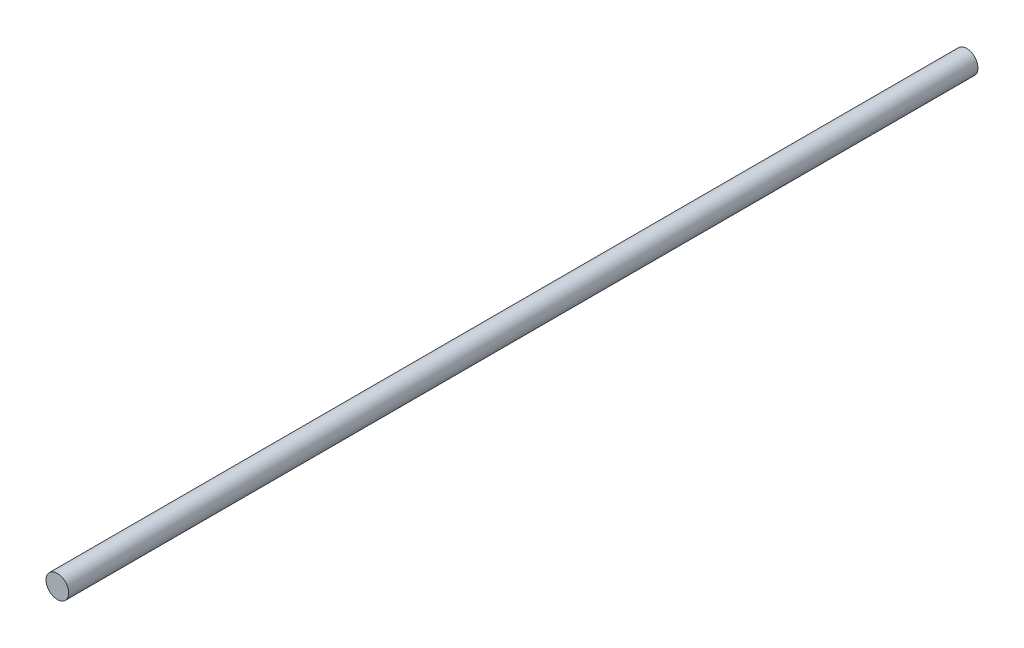
from build123d import *

# Parameters (mm, degrees)
SKETCH_1_R      = 1.25
EXTRUDE_1_DEPTH = 100


with BuildPart() as part:
    # 草圖1 → 填料-伸長1 (new body)
    with BuildSketch(Plane.XY):
        Circle(SKETCH_1_R)
    extrude(amount=EXTRUDE_1_DEPTH)


solid = part.part
